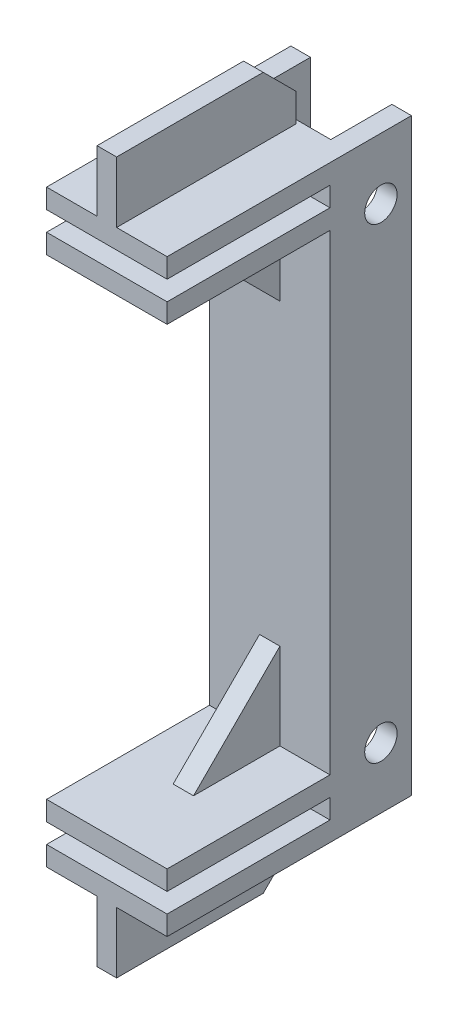
from build123d import *

# Parameters (mm, degrees)
SKETCH1_R               = 2.5273
BOSS_EXTRUDE2_DEPTH     = 9.398
BOSS_EXTRUDE3_DEPTH     = 1.524
BOSS_EXTRUDE4_DEPTH     = 1.5875
SKETCH4_W               = 12.7
SKETCH4_H               = 9.525
CUT_EXTRUDE1_DEPTH      = 56.4355
CUT_EXTRUDE1_DEPTH_BACK = 56.4355


with BuildPart() as part:
    # Sketch1 → Boss-Extrude2 (new body, symmetric)
    with BuildSketch(Plane(origin=(0, 0, 0), x_dir=(0, 0, -1), z_dir=(1, 0, 0))):
        Polygon((-6.35, -45.9105), (6.35, -45.9105), (6.35, 45.9105), (-6.35, 45.9105), (-31.75, 45.9105), (-31.75, 42.8625), (-6.35, 42.8625), (-6.35, 39.8145), (-31.75, 39.8145), (-31.75, 36.7665), (-6.35, 36.7665), (-6.35, -36.7665), (-31.75, -36.7665), (-31.75, -39.8145), (-6.35, -39.8145), (-6.35, -42.8625), (-31.75, -42.8625), (-31.75, -45.9105), align=None)
        with Locations((1.5875, 36.3855)):
            Circle(SKETCH1_R, mode=Mode.SUBTRACT)
        with Locations((1.5875, -36.3855)):
            Circle(SKETCH1_R, mode=Mode.SUBTRACT)
    extrude(amount=BOSS_EXTRUDE2_DEPTH, both=True)

    # Sketch2 → Boss-Extrude3 (add, symmetric)
    with BuildSketch(Plane(origin=(0, 0, 0), x_dir=(0, 0, -1), z_dir=(1, 0, 0))):
        Polygon((-8.89, 55.4355), (-3.81, 50.3555), (-3.81, 45.9105), (-31.75, 45.9105), (-31.75, 55.4355), align=None)
        Polygon((-31.75, -45.9105), (-31.75, -55.4355), (-8.89, -55.4355), (-3.81, -50.3555), (-3.81, -45.9105), align=None)
    extrude(amount=BOSS_EXTRUDE3_DEPTH, both=True)

    # Sketch3 → Boss-Extrude4 (add, symmetric)
    with BuildSketch(Plane(origin=(0, 0, 0), x_dir=(0, 0, -1), z_dir=(1, 0, 0))):
        Polygon((-19.820384182, 36.7665), (-6.35, 23.296115818), (-6.35, 36.7665), align=None)
        Polygon((-19.820384182, -36.7665), (-6.35, -36.7665), (-6.35, -23.296115818), align=None)
    extrude(amount=BOSS_EXTRUDE4_DEPTH, both=True)

    # Sketch4 → Cut-Extrude1 (cut, two sides)
    with BuildSketch(Plane(origin=(0, 0, 0), x_dir=(1, 0, 0), z_dir=(0, 1, 0))) as cut_extrude1_sk:
        with Locations((0, 1.5875)):
            Rectangle(SKETCH4_W, SKETCH4_H)
    extrude(amount=CUT_EXTRUDE1_DEPTH, mode=Mode.SUBTRACT)
    extrude(cut_extrude1_sk.sketch, amount=-CUT_EXTRUDE1_DEPTH_BACK, mode=Mode.SUBTRACT)


solid = part.part
